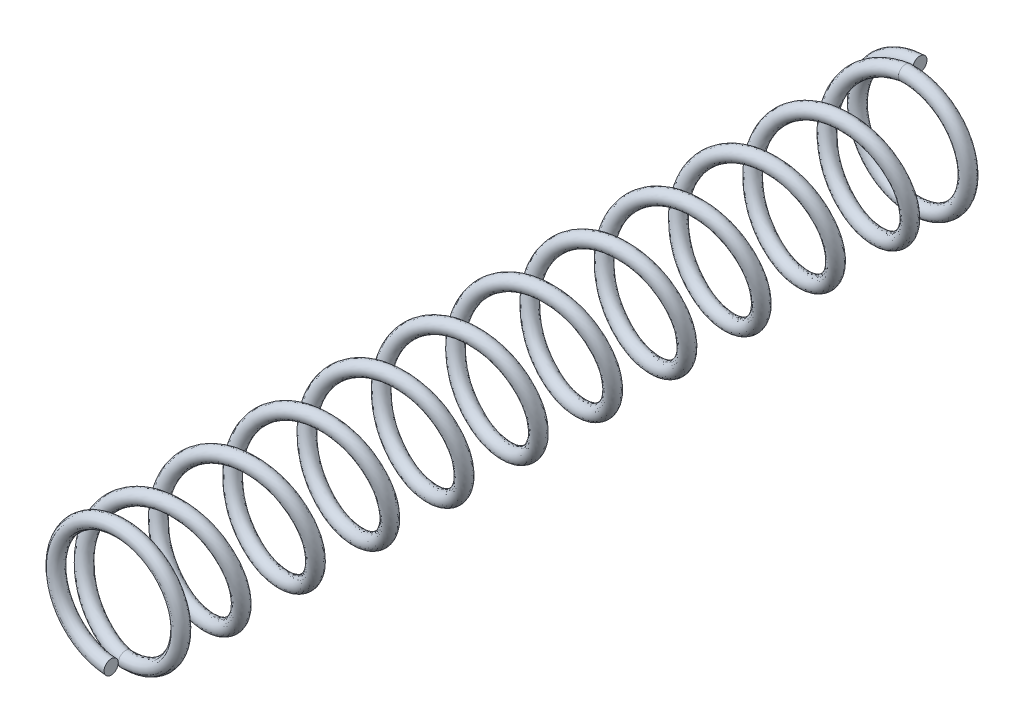
from build123d import *

# Parameters (mm, degrees)
SWEEP1_PITCH       = 0.25654
SWEEP1_HEIGHT      = 0.25654
SWEEP1_RADIUS      = 1.0541
SWEEP1_START_ANGLE = 90
SKETCH6_R          = 0.127
SWEEP2_PITCH       = 1.33096
SWEEP2_HEIGHT      = 13.97508
SWEEP2_RADIUS      = 1.0541
SWEEP2_START_ANGLE = 90
SKETCH7_R          = 0.127
SWEEP3_PITCH       = 0.25654
SWEEP3_HEIGHT      = 0.25654
SWEEP3_RADIUS      = 1.0541
SWEEP3_START_ANGLE = -90
SKETCH8_R          = 0.127


with BuildPart() as part:
    # Sweep1: sweep along a helix
    with BuildLine() as sweep1_path:
        add(Helix(SWEEP1_PITCH, SWEEP1_HEIGHT, SWEEP1_RADIUS, center=(0, 0, 0), direction=(0, 0, -1), mode=Mode.PRIVATE).rotate(Axis((0, 0, 0), (0, 0, -1)), SWEEP1_START_ANGLE))
    # Sketch6 → Sweep1 (sweep)
    with BuildSketch(Plane(origin=(0, 0, 0), x_dir=(0, 0, -1), z_dir=(1, 0, 0))):
        with Locations((0.25654, 1.0541)):
            Circle(SKETCH6_R)
    sweep(path=sweep1_path.line, is_frenet=True)

    # Sweep2: sweep along a helix
    with BuildLine() as sweep2_path:
        add(Helix(SWEEP2_PITCH, SWEEP2_HEIGHT, SWEEP2_RADIUS, center=(0, 0, 0), direction=(0, 0, 1), mode=Mode.PRIVATE).rotate(Axis((0, 0, 0), (0, 0, 1)), SWEEP2_START_ANGLE))
    # Sketch7 → Sweep2 (sweep)
    with BuildSketch(Plane.ZY):
        with Locations((0, 1.0541)):
            Circle(SKETCH7_R)
    sweep(path=sweep2_path.line, is_frenet=True)

    # Sweep3: sweep along a helix
    with BuildLine() as sweep3_path:
        add(Helix(SWEEP3_PITCH, SWEEP3_HEIGHT, SWEEP3_RADIUS, center=(0, 0, 13.97508), direction=(0, 0, 1), mode=Mode.PRIVATE).rotate(Axis((0, 0, 13.97508), (0, 0, 1)), SWEEP3_START_ANGLE))
    # Sketch8 → Sweep3 (sweep)
    with BuildSketch(Plane(origin=(0, 0, 0), x_dir=(0, 0, -1), z_dir=(1, 0, 0))):
        with Locations((-13.97508, -1.0541)):
            Circle(SKETCH8_R)
    sweep(path=sweep3_path.line, is_frenet=True)


solid = part.part
